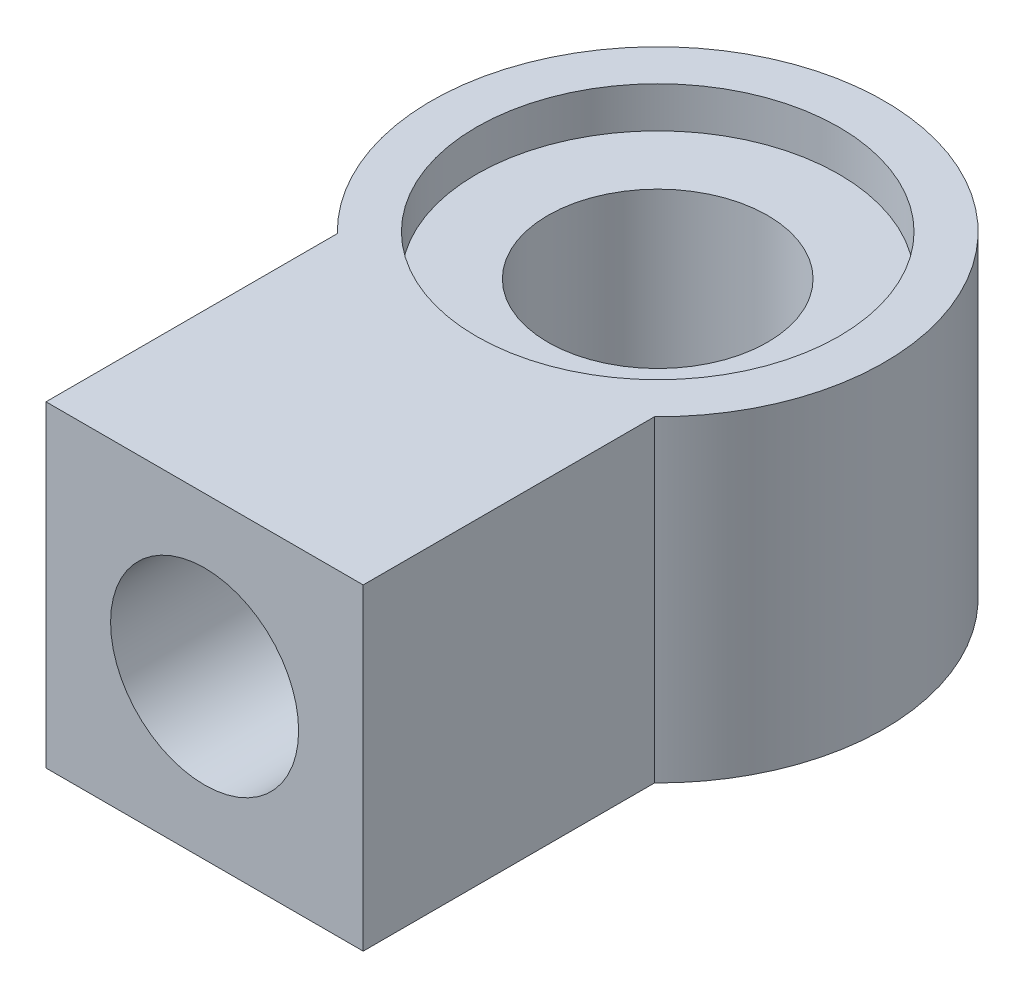
from build123d import *

# Parameters (mm, degrees)
SKETCH1_R           = 5
SKETCH1_R_2         = 2.425
BOSS_EXTRUDE1_DEPTH = 7
SKETCH2_W           = 3.5
SKETCH2_H           = 7
BOSS_EXTRUDE3_DEPTH = 1.5
SKETCH4_W           = 7
SKETCH4_H           = 7
SKETCH4_R           = 2.075
BOSS_EXTRUDE4_DEPTH = 5
SKETCH5_R           = 4
CUT_EXTRUDE1_DEPTH  = 0.9


with BuildPart() as part:
    # Sketch1 → Boss-Extrude1 (new body)
    with BuildSketch(Plane(origin=(0, 0, 0), x_dir=(1, 0, 0), z_dir=(0, 1, 0))):
        Circle(SKETCH1_R)
        Circle(SKETCH1_R_2, mode=Mode.SUBTRACT)
    extrude(amount=BOSS_EXTRUDE1_DEPTH)

    # Sketch2 → Boss-Extrude3 (add)
    with BuildSketch(Plane.XY.offset(5)):
        with Locations((-1.75, 3.5)):
            Rectangle(SKETCH2_W, SKETCH2_H)
        with Locations((1.75, 3.5)):
            Rectangle(SKETCH2_W, SKETCH2_H)
    extrude(amount=-BOSS_EXTRUDE3_DEPTH)

    # Sketch4 → Boss-Extrude4 (add)
    with BuildSketch(Plane.XY.offset(5)):
        with Locations((0, 3.5)):
            Rectangle(SKETCH4_W, SKETCH4_H)
        with Locations((0, 3.5)):
            Circle(SKETCH4_R, mode=Mode.SUBTRACT)
    extrude(amount=BOSS_EXTRUDE4_DEPTH)

    # Sketch5 → Cut-Extrude1 (cut)
    with BuildSketch(Plane(origin=(0, 7, 0), x_dir=(1, 0, 0), z_dir=(0, 1, 0))):
        Circle(SKETCH5_R)
    extrude(amount=-CUT_EXTRUDE1_DEPTH, mode=Mode.SUBTRACT)


solid = part.part
